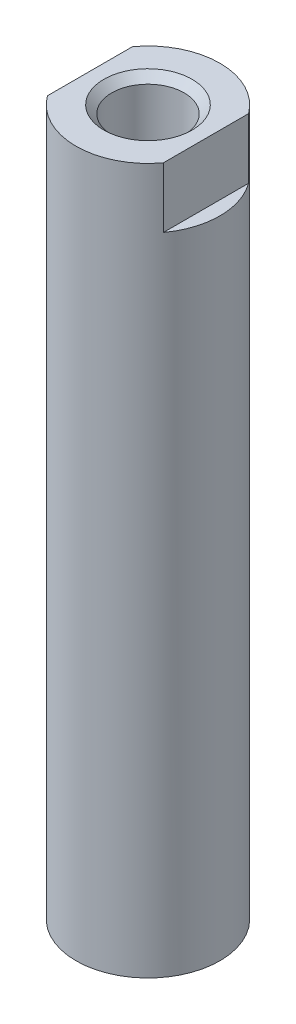
from build123d import *

# Parameters (mm, degrees)
SKETCH1_W          = 3.937
SKETCH1_H          = 38.608
HOLE1_D            = 3.96748
HOLE1_DEPTH        = 11.684
HOLE1_CSINK_D      = 4.826
HOLE1_CSINK_ANGLE  = 90
SKETCH4_W          = 12.7
SKETCH4_H          = 31.496
SKETCH4_W_2        = 6.35
SKETCH4_H_2        = 15.748
CUT_EXTRUDE1_DEPTH = 3.302


with BuildPart() as part:
    # Sketch1 → Revolve1 (revolve)
    with BuildSketch(Plane.XY):
        with Locations((1.9685, 19.304)):
            Rectangle(SKETCH1_W, SKETCH1_H)
    revolve(axis=Axis((0, 0, 0), (0, 1, 0)))

    # Hole1
    with Locations(Plane(origin=(0, 38.608, 0), x_dir=(1, 0, 0), z_dir=(0, 1, 0))):
        with Locations((0, 0)):
            CounterSinkHole(HOLE1_D / 2, HOLE1_CSINK_D / 2, depth=HOLE1_DEPTH, counter_sink_angle=HOLE1_CSINK_ANGLE)

    # Sketch4 → Cut-Extrude1 (cut)
    with BuildSketch(Plane(origin=(0, 38.608, 0), x_dir=(1, 0, 0), z_dir=(0, 1, 0))):
        Rectangle(SKETCH4_W, SKETCH4_H)
        Rectangle(SKETCH4_W_2, SKETCH4_H_2, mode=Mode.SUBTRACT)
    extrude(amount=-CUT_EXTRUDE1_DEPTH, mode=Mode.SUBTRACT)


solid = part.part
